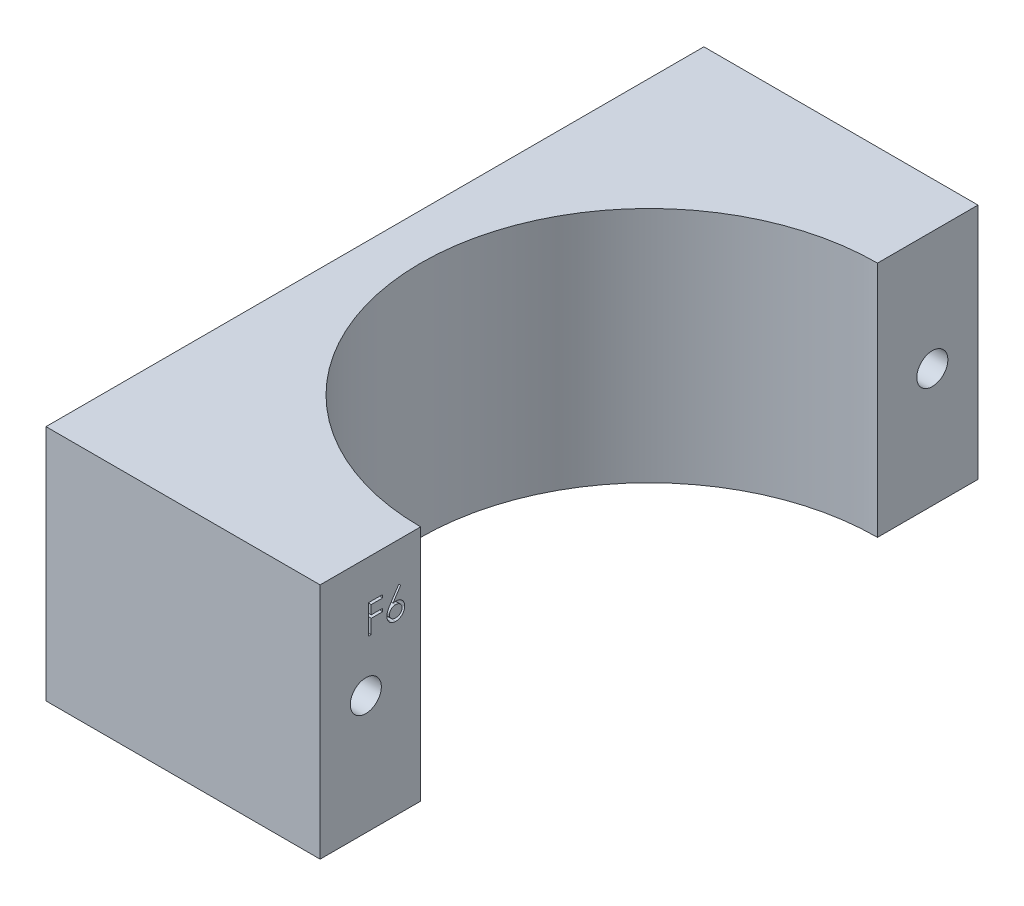
from build123d import *

# Parameters (mm, degrees)
BOSS_EXTRUDE1_DEPTH = 26
SKETCH2_R           = 1.7
CUT_EXTRUDE1_DEPTH  = 31
CUT_EXTRUDE2_DEPTH  = 1


with BuildPart() as part:
    # Sketch1 → Boss-Extrude1 (new body)
    with BuildSketch(Plane(origin=(0, 0, 0), x_dir=(1, 0, 0), z_dir=(0, 1, 0))):
        with BuildLine():
            Line((-46.998275301, 32.528571429), (-46.998275301, -39.471428571))
            Line((-46.998275301, -39.471428571), (-16.998275301, -39.471428571))
            Line((-16.998275301, -39.471428571), (-16.998275301, -28.471428571))
            ThreePointArc((-16.998275301, -28.471428571), (-41.998275301, -3.471428571), (-16.998275301, 21.528571429))
            Line((-16.998275301, 21.528571429), (-16.998275301, 32.528571429))
            Line((-16.998275301, 32.528571429), (-46.998275301, 32.528571429))
        make_face()
    extrude(amount=BOSS_EXTRUDE1_DEPTH)

    # Sketch2 → Cut-Extrude1 (cut, through all)
    with BuildSketch(Plane(origin=(-16.998275301, 0, 0), x_dir=(0, 0, -1), z_dir=(1, 0, 0))):
        with Locations((-34.471428571, 13)):
            Circle(SKETCH2_R)
        with Locations((27.528571429, 13)):
            Circle(SKETCH2_R)
    extrude(amount=-CUT_EXTRUDE1_DEPTH, mode=Mode.SUBTRACT)

    # Sketch3 → Cut-Extrude2 (cut)
    with BuildSketch(Plane(origin=(-16.998275301, 0, 0), x_dir=(0, 0, -1), z_dir=(1, 0, 0))):
        Polygon((-34.164231178, 21.664809495), (-32.617436306, 21.664809495), (-32.617436306, 21.33916847), (-33.87929528, 21.33916847), (-33.87929528, 20.362245393), (-32.617436306, 20.362245393), (-32.617436306, 20.036604367), (-33.87929528, 20.036604367), (-33.87929528, 18.489809495), (-34.164231178, 18.489809495), align=None)
        with BuildLine():
            Line((-30.867115793, 21.746219752), (-30.647053694, 21.573858975))
            Line((-30.647053694, 21.573858975), (-31.485960945, 20.291011418))
            add(Edge.make_bspline(
                [(-31.485960945, 20.291011418), (-31.430107908, 20.299913992), (-31.321160245, 20.317279468), (-31.210882608, 20.320144176), (-31.157139832, 20.321540265)],
                knots=[0, 0, 0, 0, 0.000169463, 0.000330556, 0.000330556, 0.000330556, 0.000330556], degree=3))
            add(Edge.make_bspline(
                [(-31.157139832, 20.321540265), (-31.124868872, 20.320685496), (-31.061554556, 20.319008476), (-30.968523034, 20.3057555), (-30.879108327, 20.285127316), (-30.793509908, 20.254936716), (-30.711619139, 20.216383115), (-30.632967755, 20.170173711), (-30.559033768, 20.113925858), (-30.488865205, 20.051092605), (-30.425159193, 19.981499352), (-30.368756629, 19.907656708), (-30.321379468, 19.829641624), (-30.282940267, 19.747493609), (-30.253090842, 19.661339295), (-30.231330621, 19.571288912), (-30.218467705, 19.477280362), (-30.216721009, 19.413346589), (-30.215833742, 19.380870192)],
                knots=[0, 0, 0, 0, 9.6777e-05, 0.000189873, 0.000281356, 0.000371672, 0.000461583, 0.000552553, 0.000644776, 0.000739798, 0.000834778, 0.000927384, 0.001018136, 0.001108046, 0.001198964, 0.001291213, 0.001385568, 0.001482981, 0.001482981, 0.001482981, 0.001482981], degree=3))
            add(Edge.make_bspline(
                [(-30.215833742, 19.380870192), (-30.217124701, 19.336438604), (-30.219665004, 19.249007753), (-30.244977733, 19.121666026), (-30.284311125, 19.00035153), (-30.340533597, 18.887001153), (-30.410367616, 18.781770251), (-30.495528004, 18.68852915), (-30.592994597, 18.60537133), (-30.703200478, 18.535832826), (-30.821803024, 18.479042915), (-30.946400908, 18.438253017), (-31.075784105, 18.413140155), (-31.163599713, 18.409991823), (-31.208021242, 18.408399239)],
                knots=[0, 0, 0, 0, 0.000133147, 0.000262001, 0.000387907, 0.000514768, 0.000640365, 0.000765549, 0.000892346, 0.001023614, 0.001155333, 0.001285865, 0.00141597, 0.001549154, 0.001549154, 0.001549154, 0.001549154], degree=3))
            add(Edge.make_bspline(
                [(-31.208021242, 18.408399239), (-31.250744677, 18.40978554), (-31.335372323, 18.412531559), (-31.459862072, 18.436993517), (-31.579480666, 18.476642103), (-31.693390033, 18.531265056), (-31.798909447, 18.600260421), (-31.893311845, 18.683320489), (-31.976126527, 18.778669789), (-32.045046361, 18.886293533), (-32.09970964, 19.001945137), (-32.140703357, 19.122538129), (-32.164648521, 19.247633112), (-32.167994569, 19.33243386), (-32.169679896, 19.375146034)],
                knots=[0, 0, 0, 0, 0.000128067, 0.000253679, 0.000378981, 0.000505286, 0.000631591, 0.000755981, 0.000881329, 0.001009234, 0.001138109, 0.001264215, 0.001390451, 0.001518558, 0.001518558, 0.001518558, 0.001518558], degree=3))
            add(Edge.make_bspline(
                [(-32.169679896, 19.375146034), (-32.168608156, 19.40784362), (-32.166419869, 19.474605844), (-32.151140508, 19.57571964), (-32.126588873, 19.679180265), (-32.099093149, 19.76695014), (-32.070041346, 19.838851664), (-32.045863685, 19.896821259), (-32.015770131, 19.956475947), (-31.983681421, 20.019861316), (-31.946709119, 20.085343816), (-31.906508494, 20.154017859), (-31.861968096, 20.224791265), (-31.830744092, 20.272819213), (-31.814782059, 20.297371595)],
                knots=[0, 0, 0, 0, 9.8079e-05, 0.000200258, 0.00030609, 0.000416919, 0.000475736, 0.000538705, 0.000605266, 0.000676095, 0.000751832, 0.000830806, 0.000914808, 0.001002664, 0.001002664, 0.001002664, 0.001002664], degree=3))
            Line((-31.814782059, 20.297371595), (-30.867115793, 21.746219752))
        make_face()
        with BuildLine():
            add(Edge.make_bspline(
                [(-31.216925489, 19.995899239), (-31.24111118, 19.995184076), (-31.288563308, 19.993780933), (-31.358094863, 19.985856379), (-31.423723348, 19.970840263), (-31.48620269, 19.95142058), (-31.544865998, 19.924964542), (-31.600440512, 19.893262694), (-31.652286601, 19.855281097), (-31.700151178, 19.812404161), (-31.743525509, 19.765416612), (-31.780883963, 19.71510002), (-31.813107522, 19.662653711), (-31.839307545, 19.607642956), (-31.859709233, 19.550087877), (-31.874466867, 19.490253426), (-31.882679911, 19.427738302), (-31.884046278, 19.385345247), (-31.884743998, 19.363697717)],
                knots=[0, 0, 0, 0, 7.2576e-05, 0.000142393, 0.000209516, 0.000274284, 0.000338345, 0.000402166, 0.000465901, 0.000530762, 0.000594681, 0.000657393, 0.000718477, 0.000779073, 0.000839825, 0.000901374, 0.000963619, 0.001028571, 0.001028571, 0.001028571, 0.001028571], degree=3))
            add(Edge.make_bspline(
                [(-31.884743998, 19.363697717), (-31.884175799, 19.342243806), (-31.883061645, 19.300175882), (-31.872944897, 19.238182483), (-31.857491644, 19.178524316), (-31.834504285, 19.121508938), (-31.807084179, 19.066267278), (-31.770884349, 19.014800269), (-31.730773408, 18.963982062), (-31.68282734, 18.917716442), (-31.631371146, 18.874666504), (-31.576397198, 18.837037988), (-31.519102092, 18.80484696), (-31.458712302, 18.779618321), (-31.396084625, 18.758913432), (-31.330697265, 18.744343376), (-31.262504746, 18.736106042), (-31.216311274, 18.734737895), (-31.192756819, 18.734040265)],
                knots=[0, 0, 0, 0, 6.4316e-05, 0.000126115, 0.000187979, 0.000248804, 0.000310245, 0.000372516, 0.000437181, 0.000504193, 0.000571946, 0.000638278, 0.00070376, 0.000768733, 0.000834302, 0.000901425, 0.000969348, 0.001040017, 0.001040017, 0.001040017, 0.001040017], degree=3))
            add(Edge.make_bspline(
                [(-31.192756819, 18.734040265), (-31.169202402, 18.734737949), (-31.123009006, 18.736106204), (-31.054815938, 18.744342761), (-30.989430606, 18.758915691), (-30.926795559, 18.779610133), (-30.866432975, 18.804877336), (-30.809187978, 18.83683772), (-30.754733922, 18.874897913), (-30.703243949, 18.917642872), (-30.655497448, 18.964245388), (-30.614424488, 19.014346636), (-30.579333269, 19.066683241), (-30.550817971, 19.121291327), (-30.528083799, 19.178558791), (-30.512552183, 19.238173248), (-30.502456328, 19.3001783), (-30.501339303, 19.342244623), (-30.500769639, 19.363697717)],
                knots=[0, 0, 0, 0, 7.067e-05, 0.000138593, 0.000205716, 0.000271284, 0.000336258, 0.00040174, 0.000467548, 0.000535301, 0.000602313, 0.00066738, 0.000729296, 0.000791029, 0.000851854, 0.000913718, 0.000975517, 0.001039833, 0.001039833, 0.001039833, 0.001039833], degree=3))
            add(Edge.make_bspline(
                [(-30.500769639, 19.363697717), (-30.501268834, 19.385373487), (-30.502248592, 19.427915974), (-30.513330193, 19.490225471), (-30.52869938, 19.550391855), (-30.551906718, 19.608037305), (-30.582057489, 19.662933151), (-30.618779885, 19.715361265), (-30.661270923, 19.765705799), (-30.710317034, 19.812524596), (-30.763707476, 19.85501674), (-30.820114642, 19.893405283), (-30.879889589, 19.92466945), (-30.941953816, 19.951510565), (-31.007054871, 19.970532437), (-31.074481667, 19.985903262), (-31.144873114, 19.993714686), (-31.192741951, 19.995166019), (-31.216925489, 19.995899239)],
                knots=[0, 0, 0, 0, 6.4952e-05, 0.000127479, 0.000189343, 0.000250994, 0.000313327, 0.000376843, 0.000442725, 0.000510648, 0.000579881, 0.000647266, 0.000714983, 0.000781961, 0.000849765, 0.00091813, 0.000989211, 0.001061786, 0.001061786, 0.001061786, 0.001061786], degree=3))
        make_face(mode=Mode.SUBTRACT)
    extrude(amount=-CUT_EXTRUDE2_DEPTH, mode=Mode.SUBTRACT)


solid = part.part
